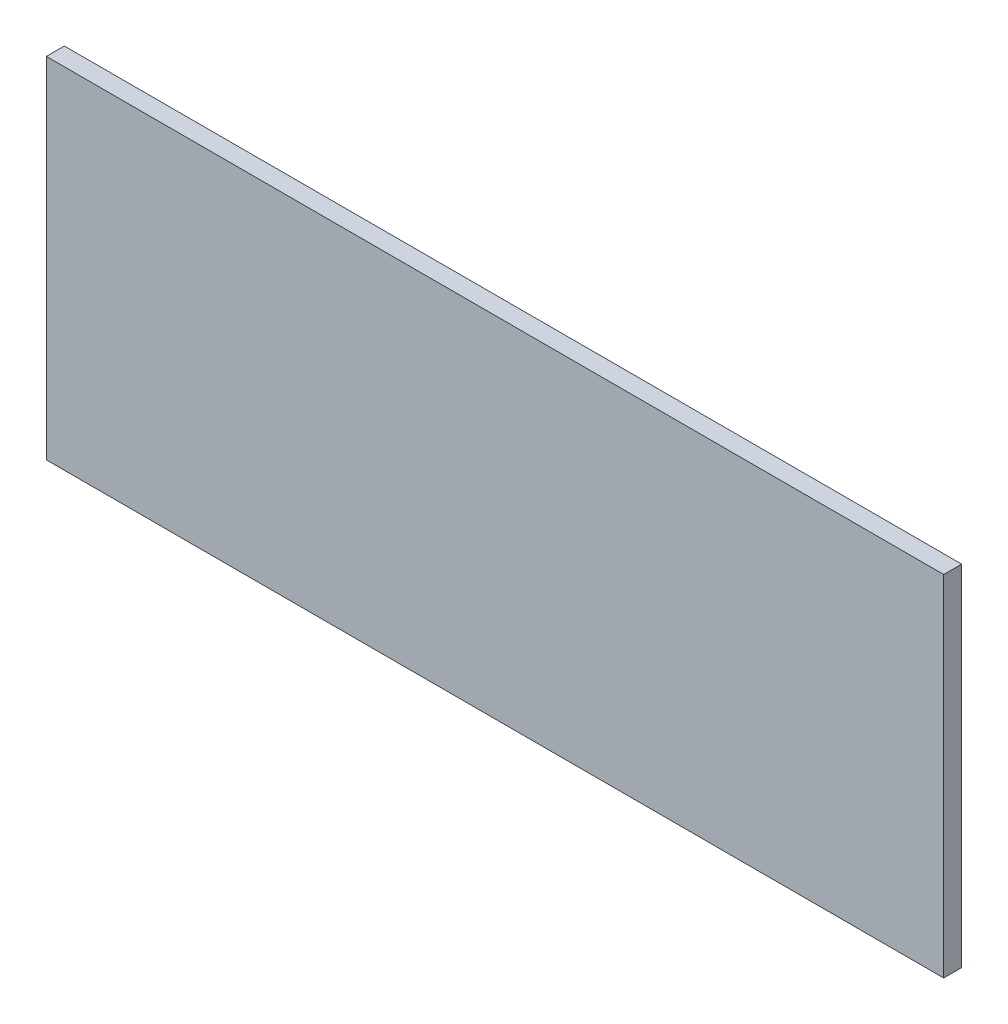
from build123d import *

# Parameters (mm, degrees)
SKETCH1_W           = 249.6
SKETCH1_H           = 97.192233147
BOSS_EXTRUDE1_DEPTH = 5


with BuildPart() as part:
    # Sketch1 → Boss-Extrude1 (new body)
    with BuildSketch(Plane.XY):
        with Locations((124.8, -48.596116574)):
            Rectangle(SKETCH1_W, SKETCH1_H)
    extrude(amount=BOSS_EXTRUDE1_DEPTH)


solid = part.part
